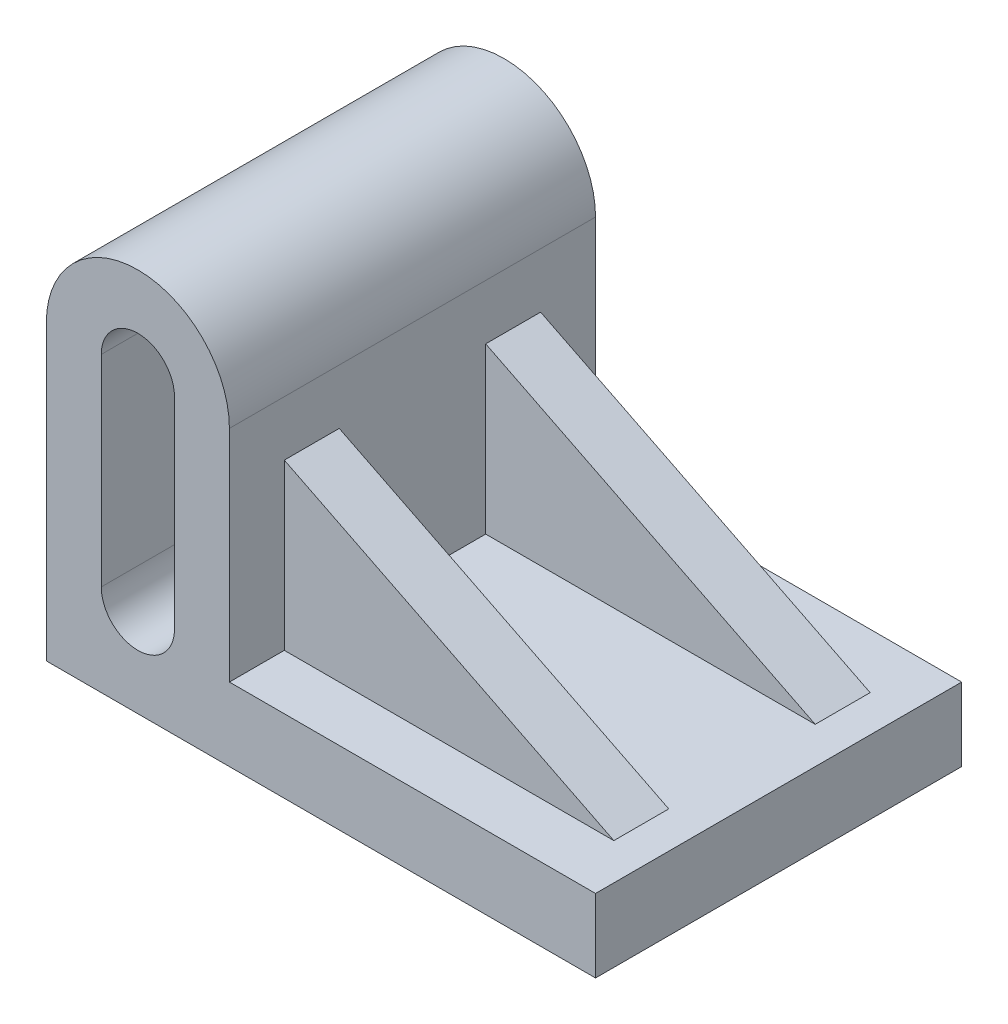
from build123d import *

# Parameters (mm, degrees)
BOSS_EXTRUDE1_DEPTH      = 50
BOSS_EXTRUDE1_DEPTH_BACK = 50
CUT_EXTRUDE1_DEPTH       = 209.62646045
BOSS_EXTRUDE2_DEPTH      = 35
BOSS_EXTRUDE2_DEPTH_BACK = 35
SKETCH4_W                = 100
SKETCH4_H                = 40
CUT_EXTRUDE2_DEPTH       = 180.51323071


with BuildPart() as part:
    # Sketch1 → Boss-Extrude1 (new, two sides: drawn at the far end of the back side and taken through both)
    with BuildSketch(Plane.XY.offset(-BOSS_EXTRUDE1_DEPTH_BACK)):
        with BuildLine():
            Line((0, 0), (150, 0))
            Line((150, 0), (150, 20))
            Line((150, 20), (50, 20))
            Line((50, 20), (50, 80))
            ThreePointArc((50, 80), (25, 105), (0, 80))
            Line((0, 80), (0, 0))
        make_face()
    extrude(amount=BOSS_EXTRUDE1_DEPTH + BOSS_EXTRUDE1_DEPTH_BACK)

    # Sketch2 → Cut-Extrude1 (cut, through all)
    with BuildSketch(Plane.XY.offset(50)):
        with BuildLine():
            Line((35, 80), (35, 25))
            ThreePointArc((35, 25), (25, 15), (15, 25))
            Line((15, 25), (15, 80))
            ThreePointArc((15, 80), (25, 90), (35, 80))
        make_face()
    extrude(amount=-CUT_EXTRUDE1_DEPTH, mode=Mode.SUBTRACT)

    # Sketch3 → Boss-Extrude2 (add, two sides: drawn at the far end of the back side and taken through both)
    with BuildSketch(Plane.XY.offset(-BOSS_EXTRUDE2_DEPTH_BACK)):
        Polygon((50, 65), (50, 20), (140, 20), align=None)
    extrude(amount=BOSS_EXTRUDE2_DEPTH + BOSS_EXTRUDE2_DEPTH_BACK)

    # Sketch4 → Cut-Extrude2 (cut, through all)
    with BuildSketch(Plane(origin=(0, 20, 0), x_dir=(1, 0, 0), z_dir=(0, 1, 0))):
        with Locations((100, 0)):
            Rectangle(SKETCH4_W, SKETCH4_H)
    extrude(amount=CUT_EXTRUDE2_DEPTH, mode=Mode.SUBTRACT)


solid = part.part
